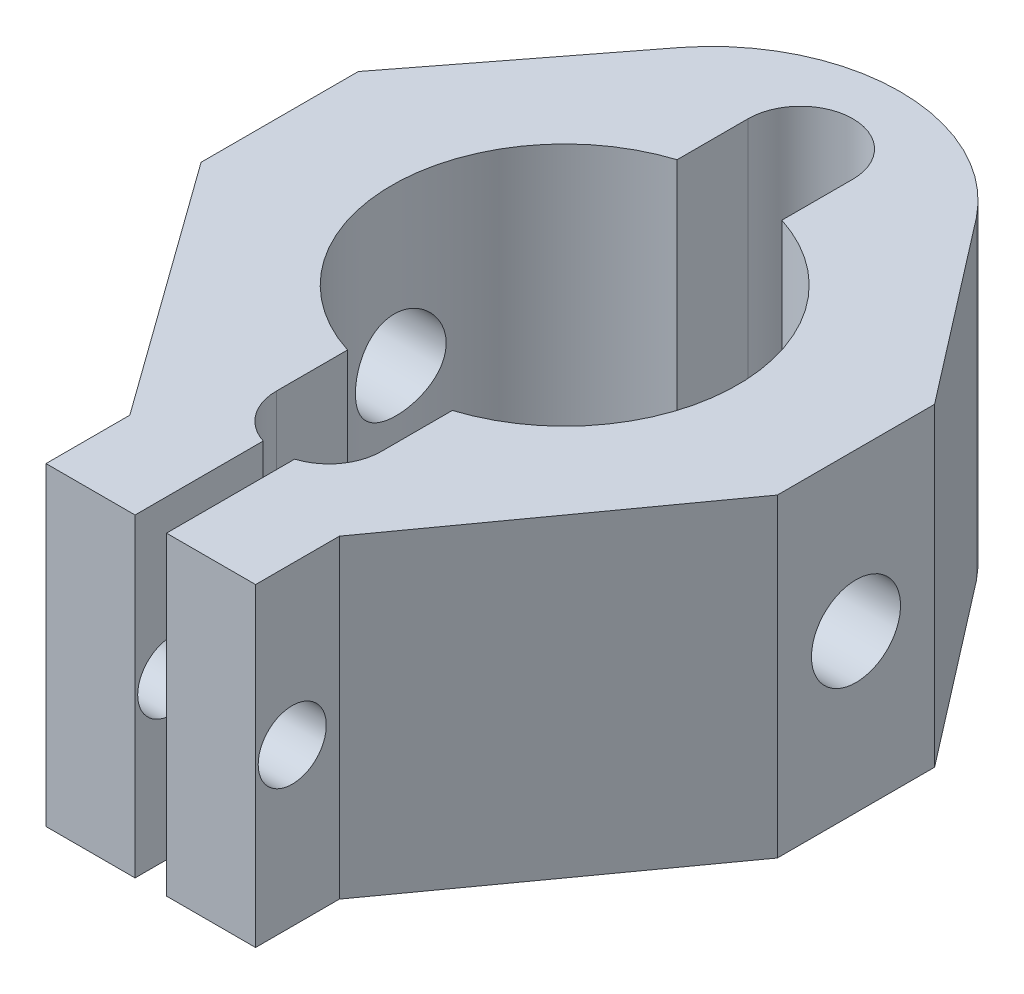
from build123d import *

# Parameters (mm, degrees)
BOSS_EXTRUDE2_DEPTH = 30
SKETCH2_R           = 4.25
CUT_EXTRUDE1_DEPTH  = 55.999999228
SKETCH5_R           = 3.25
CUT_EXTRUDE2_DEPTH  = 30


with BuildPart() as part:
    # Sketch1 → Boss-Extrude2 (new body)
    with BuildSketch(Plane(origin=(0, 0, 0), x_dir=(1, 0, 0), z_dir=(0, 1, 0))):
        with BuildLine():
            Line((-1.499999614, -22.769695991), (-1.499999614, -34.999999869))
            Line((-1.499999614, -34.999999869), (-9.999999614, -34.999999869))
            Line((-9.999999614, -34.999999869), (-9.999999614, -26.999999869))
            Line((-9.999999614, -26.999999869), (-27.499999614, -2.699999869))
            Line((-27.499999614, -2.699999869), (-27.499999614, 12.300000131))
            Line((-27.499999614, 12.300000131), (-14.093884058, 29.689647964))
            ThreePointArc((-14.093884058, 29.689647964), (0, 36.500000672), (14.093884058, 29.689647964))
            Line((14.093884058, 29.689647964), (27.499999614, 12.300000131))
            Line((27.499999614, 12.300000131), (27.499999614, -2.699999869))
            Line((27.499999614, -2.699999869), (9.999999344, -26.999999675))
            Line((9.999999344, -26.999999675), (9.999999344, -34.999999869))
            Line((9.999999344, -34.999999869), (1.500000386, -34.999999869))
            Line((1.500000386, -34.999999869), (1.500000386, -22.769695748))
            ThreePointArc((1.500000386, -22.769695748), (4.0311289, -20.958039634), (4.999999869, -18))
            Line((4.999999869, -18), (4.999999869, -11.224185235))
            ThreePointArc((4.999999869, -11.224185235), (16.5, 4.5), (4.999999869, 20.224185235))
            Line((4.999999869, 20.224185235), (4.999999869, 27))
            ThreePointArc((4.999999869, 27), (0, 31.999999869), (-4.999999869, 27))
            Line((-4.999999869, 27), (-4.999999869, 20.224185235))
            ThreePointArc((-4.999999869, 20.224185235), (-16.5, 4.5), (-4.999999869, -11.224185235))
            Line((-4.999999869, -11.224185235), (-4.999999869, -18))
            ThreePointArc((-4.999999869, -18), (-4.031128661, -20.95803996), (-1.499999614, -22.769695991))
        make_face()
    extrude(amount=BOSS_EXTRUDE2_DEPTH)

    # Sketch2 → Cut-Extrude1 (cut, through all)
    with BuildSketch(Plane.ZY.offset(27.499999614)):
        with Locations((-4.800000131, 15)):
            Circle(SKETCH2_R)
    extrude(amount=-CUT_EXTRUDE1_DEPTH, mode=Mode.SUBTRACT)

    # Sketch5 → Cut-Extrude2 (cut)
    with BuildSketch(Plane.ZY.offset(9.999999614)):
        with Locations((31.499999869, 15)):
            Circle(SKETCH5_R)
    extrude(amount=-CUT_EXTRUDE2_DEPTH, mode=Mode.SUBTRACT)


solid = part.part
